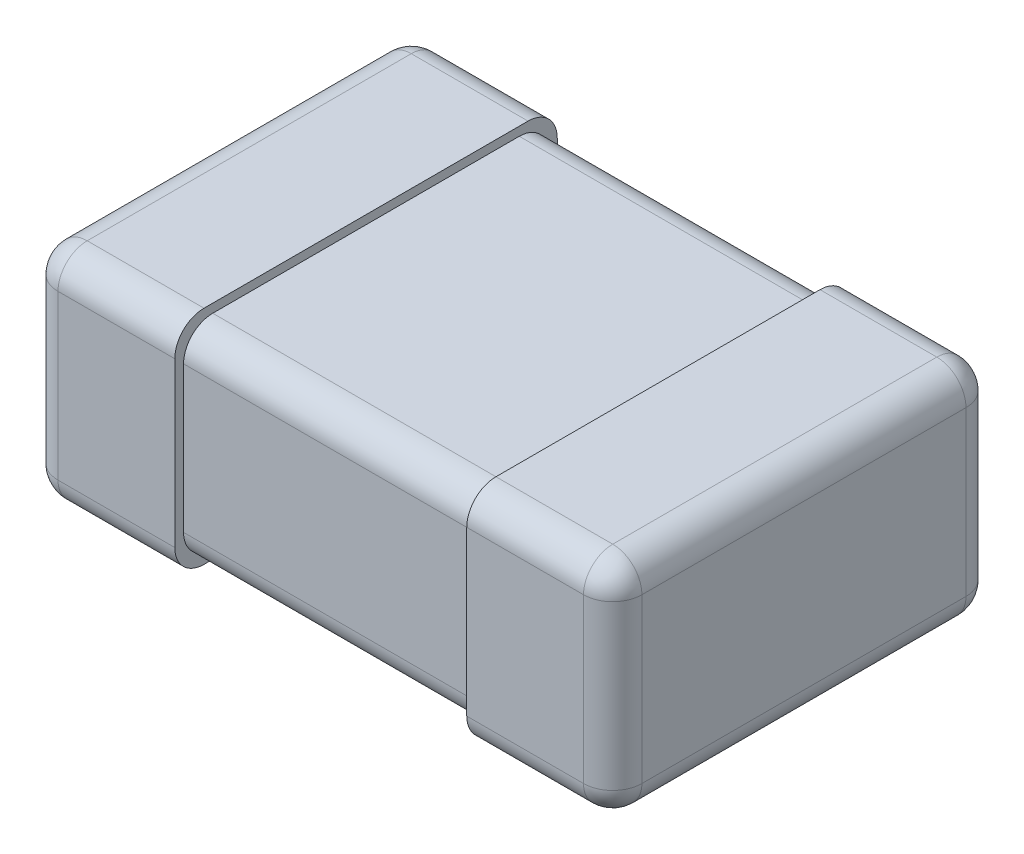
from build123d import *

# Parameters (mm, degrees)
SKETCH1_W           = 2
SKETCH1_H           = 1.25
EXTRUDE1_DEPTH      = 0.7
SKETCH2_W           = 0.5
SKETCH2_H           = 0.76
EXTRUDE2_DEPTH      = 0.655
EXTRUDE2_DEPTH_BACK = 0.655
FILLET1_R           = 0.1


with BuildPart() as part:
    # Sketch1 → Extrude1 (new body)
    with BuildSketch(Plane(origin=(0, 0, 0), x_dir=(1, 0, 0), z_dir=(0, 1, 0))):
        Rectangle(SKETCH1_W, SKETCH1_H)
    extrude(amount=EXTRUDE1_DEPTH)

    # Sketch2 → Extrude2 (add, two sides)
    with BuildSketch(Plane.XY) as extrude2_sk:
        with Locations((-0.75, 0.35)):
            Rectangle(SKETCH2_W, SKETCH2_H)
        with Locations((0.75, 0.35)):
            Rectangle(SKETCH2_W, SKETCH2_H)
    extrude(amount=EXTRUDE2_DEPTH)
    extrude(extrude2_sk.sketch, amount=-EXTRUDE2_DEPTH_BACK)

    # Fillet1
    fillet1_edges = [part.edges().sort_by_distance(p)[0] for p in [
        (-1, 0.35, 0.655),
        (-1, 0.73, 0),
        (-1, 0.35, -0.655),
        (-1, -0.03, 0),
        (-0.75, 0.73, 0.655),
        (-0.75, -0.03, 0.655),
        (-0.75, 0.73, -0.655),
        (-0.75, -0.03, -0.655),
        (0, 0, 0.625),
        (0, 0, -0.625),
        (0, 0.7, 0.625),
        (0, 0.7, -0.625),
        (1, -0.03, 0),
        (0.75, -0.03, 0.655),
        (0.75, -0.03, -0.655),
        (1, 0.35, 0.655),
        (0.75, 0.73, 0.655),
        (1, 0.35, -0.655),
        (0.75, 0.73, -0.655),
        (1, 0.73, 0),
    ]]
    fillet(fillet1_edges, radius=FILLET1_R)


solid = part.part
